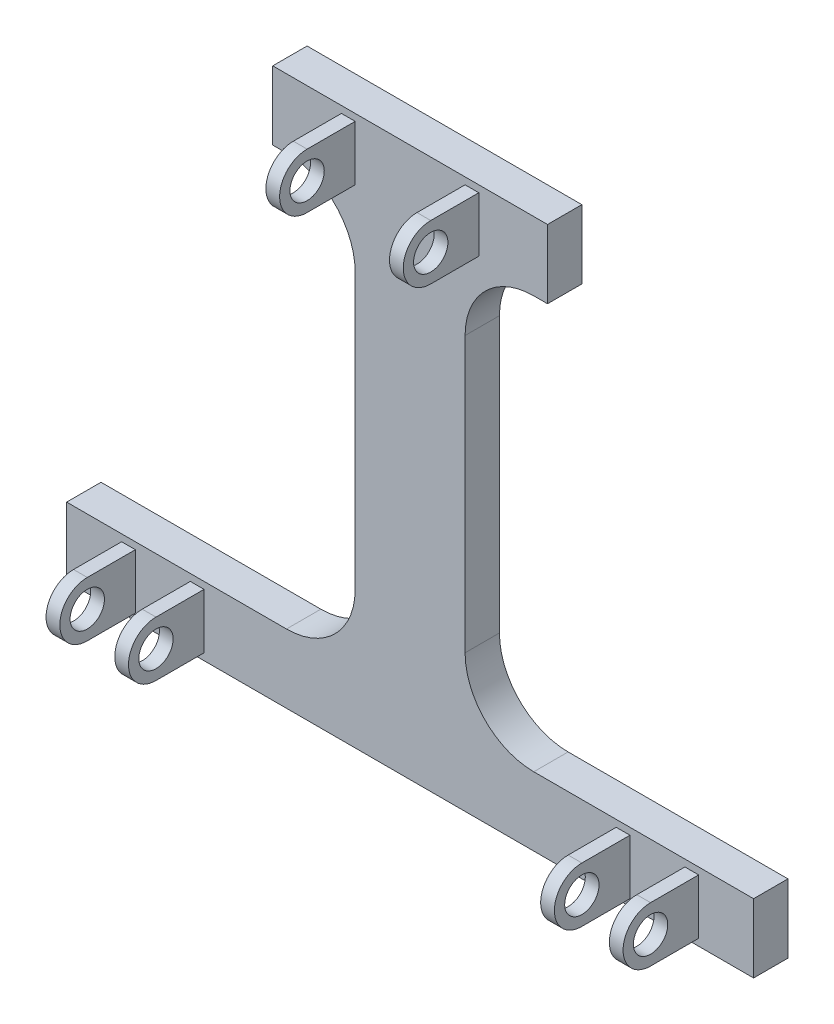
from build123d import *

# Parameters (mm, degrees)
BOSS_EXTRUDE1_DEPTH     = 5
SKETCH4_W               = 2
SKETCH4_H               = 8
BOSS_EXTRUDE2_DEPTH     = 12
SKETCH5_R               = 2.5
CUT_EXTRUDE1_DEPTH      = 51
CUT_EXTRUDE1_DEPTH_BACK = 51


with BuildPart() as part:
    # Sketch2 → Boss-Extrude1 (new body)
    with BuildSketch(Plane.XY):
        with BuildLine():
            Line((-20, 80), (20, 80))
            Line((20, 80), (20, 70))
            Line((20, 70), (18, 70))
            ThreePointArc((18, 70), (10.928932188, 67.071067812), (8, 60))
            Line((8, 60), (8, 20))
            ThreePointArc((8, 20), (10.928932188, 12.928932188), (18, 10))
            Line((18, 10), (50, 10))
            Line((50, 10), (50, 0))
            Line((50, 0), (-50, 0))
            Line((-50, 0), (-50, 10))
            Line((-50, 10), (-18, 10))
            ThreePointArc((-18, 10), (-10.928932188, 12.928932188), (-8, 20))
            Line((-8, 20), (-8, 60))
            ThreePointArc((-8, 60), (-10.928932188, 67.071067812), (-18, 70))
            Line((-18, 70), (-20, 70))
            Line((-20, 70), (-20, 80))
        make_face()
    extrude(amount=BOSS_EXTRUDE1_DEPTH)

    # Sketch4 → Boss-Extrude2 (add)
    with BuildSketch(Plane.XY.offset(5)):
        with Locations((-9, 75)):
            Rectangle(SKETCH4_W, SKETCH4_H)
        with Locations((9, 75)):
            Rectangle(SKETCH4_W, SKETCH4_H)
        with Locations((-41, 5)):
            Rectangle(SKETCH4_W, SKETCH4_H)
        with Locations((-31, 5)):
            Rectangle(SKETCH4_W, SKETCH4_H)
        with Locations((31, 5)):
            Rectangle(SKETCH4_W, SKETCH4_H)
        with Locations((41, 5)):
            Rectangle(SKETCH4_W, SKETCH4_H)
    extrude(amount=BOSS_EXTRUDE2_DEPTH)

    # Sketch5 → Cut-Extrude1 (cut, two sides)
    with BuildSketch(Plane(origin=(0, 0, 0), x_dir=(0, 0, -1), z_dir=(1, 0, 0))) as cut_extrude1_sk:
        with Locations((-12, 75)):
            Circle(SKETCH5_R)
        with Locations((-12, 5)):
            Circle(SKETCH5_R)
        with BuildLine():
            Line((-12, 79), (-17, 79))
            Line((-17, 79), (-17, 71))
            Line((-17, 71), (-12, 71))
            ThreePointArc((-12, 71), (-16, 75), (-12, 79))
        make_face()
        with BuildLine():
            Line((-12, 9), (-17, 9))
            Line((-17, 9), (-17, 1))
            Line((-17, 1), (-12, 1))
            ThreePointArc((-12, 1), (-16, 5), (-12, 9))
        make_face()
    extrude(amount=CUT_EXTRUDE1_DEPTH, mode=Mode.SUBTRACT)
    extrude(cut_extrude1_sk.sketch, amount=-CUT_EXTRUDE1_DEPTH_BACK, mode=Mode.SUBTRACT)


solid = part.part
